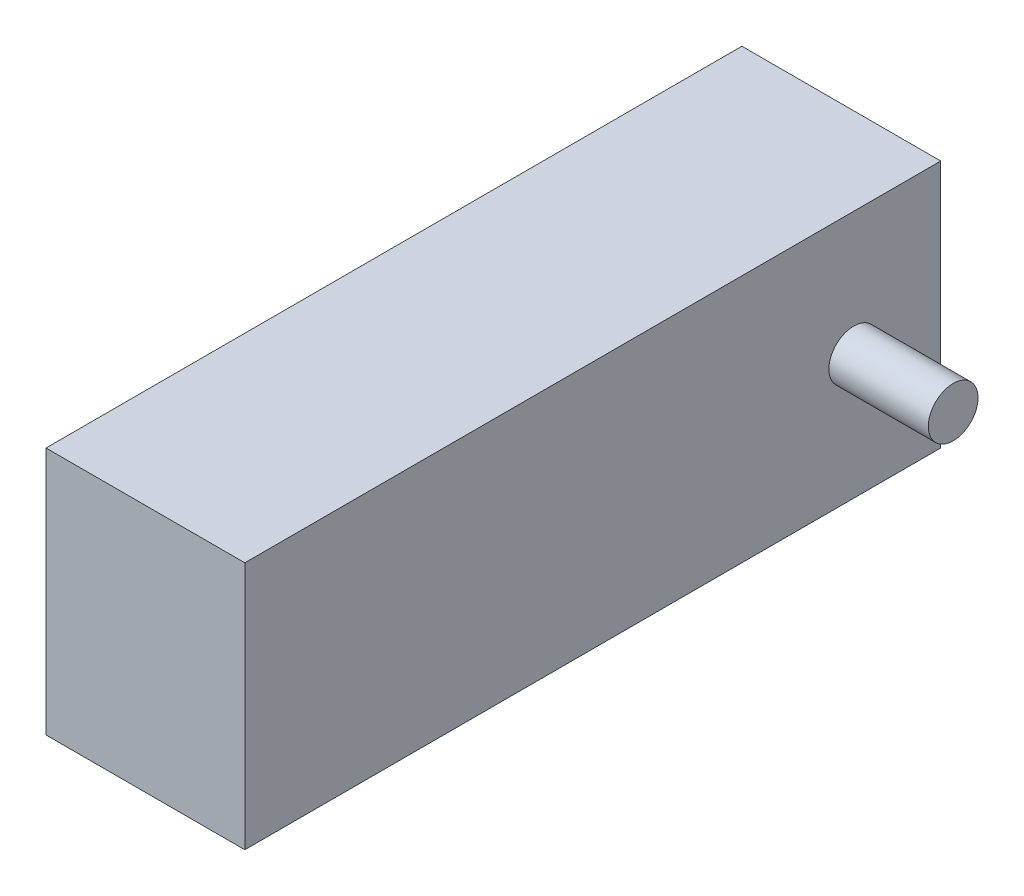
from build123d import *

# Parameters (mm, degrees)
SKETCH_1_W             = 20
SKETCH_1_H             = 70
EXTRUDE_326_DEPTH      = 25
SKETCH_2_R             = 2.5
EXTRUDE_591_DEPTH      = 10
EXTRUDE_591_DEPTH_BACK = 30


with BuildPart() as part:
    # Эскиз1 → Extrude 326 (new body)
    with BuildSketch(Plane(origin=(0, 0, 0), x_dir=(1, 0, 0), z_dir=(0, 1, 0))):
        with Locations((-10, 35)):
            Rectangle(SKETCH_1_W, SKETCH_1_H)
    extrude(amount=EXTRUDE_326_DEPTH)

    # Эскиз2 → Extrude 591 (add, two sides)
    with BuildSketch(Plane(origin=(0, 0, 0), x_dir=(0, 0, -1), z_dir=(1, 0, 0))) as extrude_591_sk:
        with Locations((61.25, 12.5)):
            Circle(SKETCH_2_R)
    extrude(amount=EXTRUDE_591_DEPTH)
    extrude(extrude_591_sk.sketch, amount=-EXTRUDE_591_DEPTH_BACK)


solid = part.part
